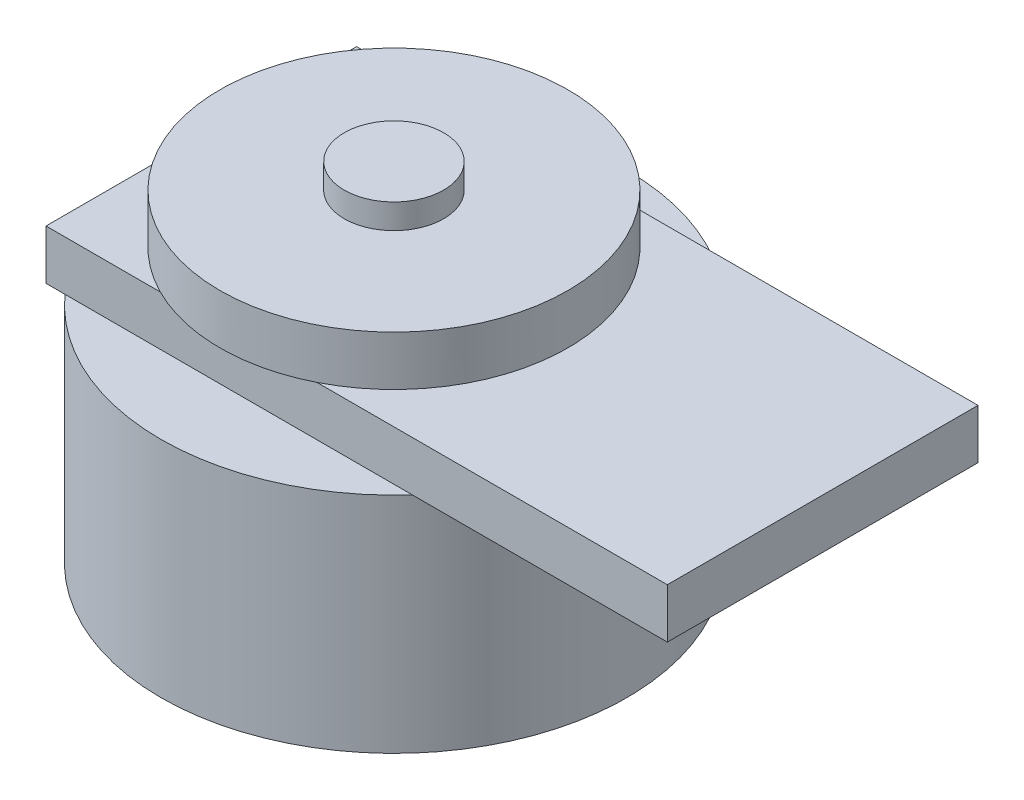
from build123d import *

# Parameters (mm, degrees)
SKETCH1_W           = 50
SKETCH1_H           = 25
BOSS_EXTRUDE1_DEPTH = 4
SKETCH2_R           = 14
BOSS_EXTRUDE2_DEPTH = 4
SKETCH3_R           = 4
BOSS_EXTRUDE3_DEPTH = 2
SKETCH4_R           = 18.75
BOSS_EXTRUDE4_DEPTH = 18


with BuildPart() as part:
    # Sketch1 → Boss-Extrude1 (new body)
    with BuildSketch(Plane(origin=(0, 0, 0), x_dir=(1, 0, 0), z_dir=(0, 1, 0))):
        Rectangle(SKETCH1_W, SKETCH1_H)
    extrude(amount=BOSS_EXTRUDE1_DEPTH)

    # Sketch2 → Boss-Extrude2 (add)
    with BuildSketch(Plane(origin=(0, 4, 0), x_dir=(1, 0, 0), z_dir=(0, 1, 0))):
        with Locations((-9.5, 0)):
            Circle(SKETCH2_R)
    extrude(amount=BOSS_EXTRUDE2_DEPTH)

    # Sketch3 → Boss-Extrude3 (add)
    with BuildSketch(Plane(origin=(0, 8, 0), x_dir=(1, 0, 0), z_dir=(0, 1, 0))):
        with Locations((-9.5, 0)):
            Circle(SKETCH3_R)
    extrude(amount=BOSS_EXTRUDE3_DEPTH)

    # Sketch4 → Boss-Extrude4 (add)
    with BuildSketch(Plane.XZ):
        with Locations((-9.5, 0)):
            Circle(SKETCH4_R)
    extrude(amount=BOSS_EXTRUDE4_DEPTH)


solid = part.part
